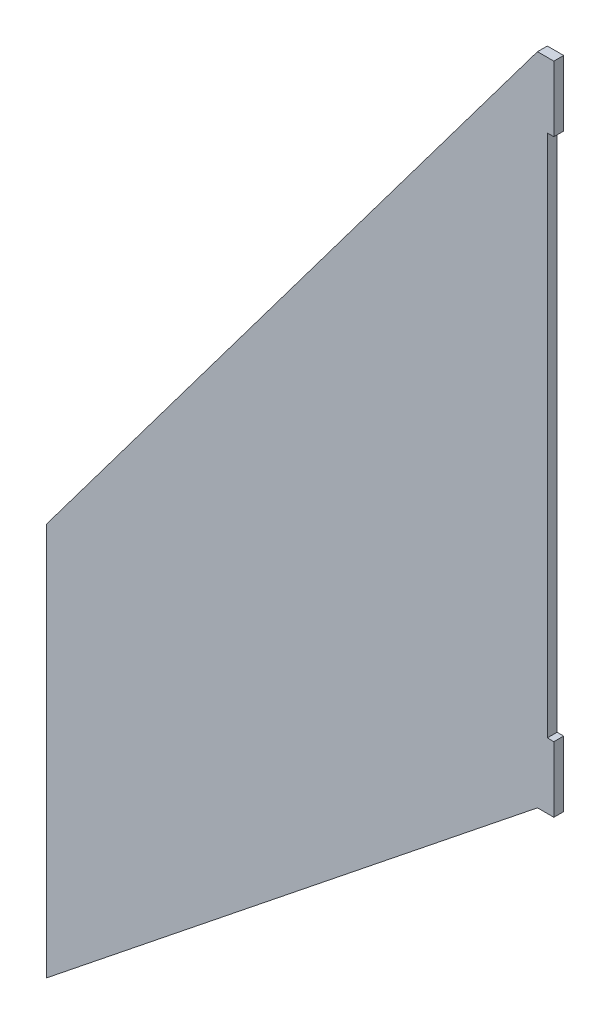
from build123d import *

# Parameters (mm, degrees)
BOSS_EXTRU_1_DEPTH = 3


with BuildPart() as part:
    # Esquisse1 → Boss.-Extru.1 (new body)
    with BuildSketch(Plane.XY):
        Polygon((0, 0), (-5, 0), (-155, -200), (-155, -320), (-5, -200), (0, -200), (0, -180), (-2, -180), (-2, -20), (0, -20), align=None)
    extrude(amount=BOSS_EXTRU_1_DEPTH)


solid = part.part
